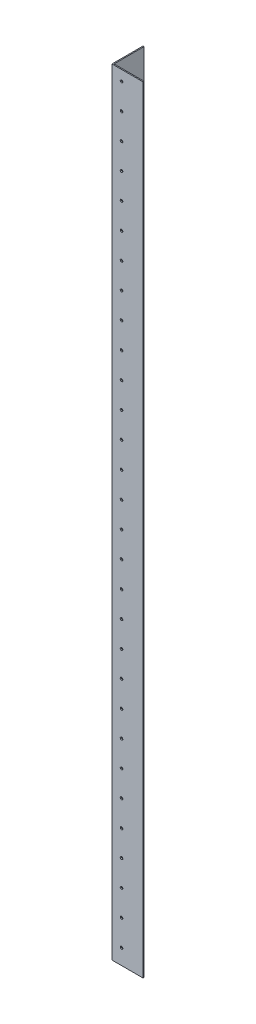
from build123d import *

# Parameters (mm, degrees)
EXTRUDE_1_DEPTH     = 1500
SKETCH_2_R          = 2.5
CUT_EXTRUDE_1_DEPTH = 61
SKETCH_3_R          = 2.5
CUT_EXTRUDE_2_DEPTH = 61


with BuildPart() as part:
    # Эскиз1 → Вытянуть-Тонкостенный1 (new body)
    with BuildSketch(Plane(origin=(0, 0, 0), x_dir=(1, 0, 0), z_dir=(0, 1, 0))):
        Polygon((0, 60), (0, 0), (60, 0), (60, 2), (2, 2), (2, 60), align=None)
    extrude(amount=EXTRUDE_1_DEPTH)

    # Эскиз2 → Вырез-Вытянуть1 (cut, through all)
    with BuildSketch(Plane.ZY):
        with Locations((-18.5, 30)):
            Circle(SKETCH_2_R)
        with Locations((-18.5, 80)):
            Circle(SKETCH_2_R)
        with Locations((-18.5, 130)):
            Circle(SKETCH_2_R)
        with Locations((-18.5, 180)):
            Circle(SKETCH_2_R)
        with Locations((-18.5, 230)):
            Circle(SKETCH_2_R)
        with Locations((-18.5, 280)):
            Circle(SKETCH_2_R)
        with Locations((-18.5, 330)):
            Circle(SKETCH_2_R)
        with Locations((-18.5, 380)):
            Circle(SKETCH_2_R)
        with Locations((-18.5, 430)):
            Circle(SKETCH_2_R)
        with Locations((-18.5, 480)):
            Circle(SKETCH_2_R)
        with Locations((-18.5, 530)):
            Circle(SKETCH_2_R)
        with Locations((-18.5, 580)):
            Circle(SKETCH_2_R)
        with Locations((-18.5, 630)):
            Circle(SKETCH_2_R)
        with Locations((-18.5, 680)):
            Circle(SKETCH_2_R)
        with Locations((-18.5, 730)):
            Circle(SKETCH_2_R)
        with Locations((-18.5, 780)):
            Circle(SKETCH_2_R)
        with Locations((-18.5, 830)):
            Circle(SKETCH_2_R)
        with Locations((-18.5, 880)):
            Circle(SKETCH_2_R)
        with Locations((-18.5, 930)):
            Circle(SKETCH_2_R)
        with Locations((-18.5, 980)):
            Circle(SKETCH_2_R)
        with Locations((-18.5, 1030)):
            Circle(SKETCH_2_R)
        with Locations((-18.5, 1080)):
            Circle(SKETCH_2_R)
        with Locations((-18.5, 1130)):
            Circle(SKETCH_2_R)
        with Locations((-18.5, 1180)):
            Circle(SKETCH_2_R)
        with Locations((-18.5, 1230)):
            Circle(SKETCH_2_R)
        with Locations((-18.5, 1280)):
            Circle(SKETCH_2_R)
        with Locations((-18.5, 1330)):
            Circle(SKETCH_2_R)
        with Locations((-18.5, 1380)):
            Circle(SKETCH_2_R)
        with Locations((-18.5, 1430)):
            Circle(SKETCH_2_R)
        with Locations((-18.5, 1480)):
            Circle(SKETCH_2_R)
    extrude(amount=-CUT_EXTRUDE_1_DEPTH, mode=Mode.SUBTRACT)

    # Эскиз3 → Вырез-Вытянуть2 (cut, through all)
    with BuildSketch(Plane.XY):
        with Locations((18.5, 30)):
            Circle(SKETCH_3_R)
        with Locations((18.5, 80)):
            Circle(SKETCH_3_R)
        with Locations((18.5, 130)):
            Circle(SKETCH_3_R)
        with Locations((18.5, 180)):
            Circle(SKETCH_3_R)
        with Locations((18.5, 230)):
            Circle(SKETCH_3_R)
        with Locations((18.5, 280)):
            Circle(SKETCH_3_R)
        with Locations((18.5, 330)):
            Circle(SKETCH_3_R)
        with Locations((18.5, 380)):
            Circle(SKETCH_3_R)
        with Locations((18.5, 430)):
            Circle(SKETCH_3_R)
        with Locations((18.5, 480)):
            Circle(SKETCH_3_R)
        with Locations((18.5, 530)):
            Circle(SKETCH_3_R)
        with Locations((18.5, 580)):
            Circle(SKETCH_3_R)
        with Locations((18.5, 630)):
            Circle(SKETCH_3_R)
        with Locations((18.5, 680)):
            Circle(SKETCH_3_R)
        with Locations((18.5, 730)):
            Circle(SKETCH_3_R)
        with Locations((18.5, 780)):
            Circle(SKETCH_3_R)
        with Locations((18.5, 830)):
            Circle(SKETCH_3_R)
        with Locations((18.5, 880)):
            Circle(SKETCH_3_R)
        with Locations((18.5, 930)):
            Circle(SKETCH_3_R)
        with Locations((18.5, 980)):
            Circle(SKETCH_3_R)
        with Locations((18.5, 1030)):
            Circle(SKETCH_3_R)
        with Locations((18.5, 1080)):
            Circle(SKETCH_3_R)
        with Locations((18.5, 1130)):
            Circle(SKETCH_3_R)
        with Locations((18.5, 1180)):
            Circle(SKETCH_3_R)
        with Locations((18.5, 1230)):
            Circle(SKETCH_3_R)
        with Locations((18.5, 1280)):
            Circle(SKETCH_3_R)
        with Locations((18.5, 1330)):
            Circle(SKETCH_3_R)
        with Locations((18.5, 1380)):
            Circle(SKETCH_3_R)
        with Locations((18.5, 1430)):
            Circle(SKETCH_3_R)
        with Locations((18.5, 1480)):
            Circle(SKETCH_3_R)
    extrude(amount=-CUT_EXTRUDE_2_DEPTH, mode=Mode.SUBTRACT)


solid = part.part
